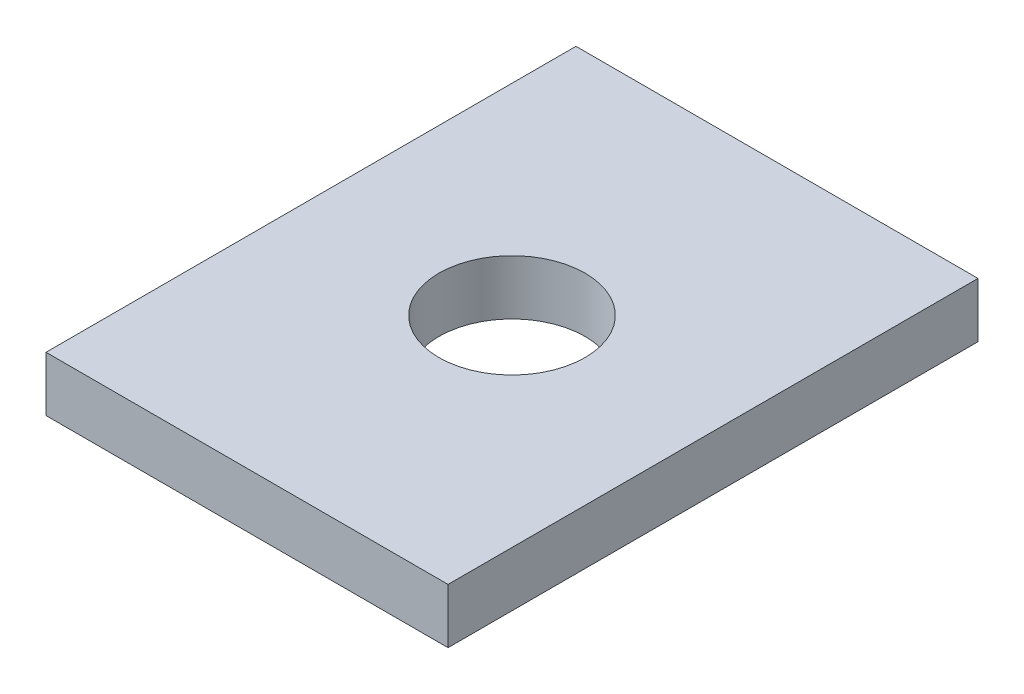
from build123d import *

# Parameters (mm, degrees)
SKETCH1_W           = 139.7
SKETCH1_H           = 184.15
SKETCH1_R           = 25.4
BOSS_EXTRUDE1_DEPTH = 19.05


with BuildPart() as part:
    # Sketch1 → Boss-Extrude1 (new body)
    with BuildSketch(Plane(origin=(0, 0, 0), x_dir=(1, 0, 0), z_dir=(0, 1, 0))):
        Rectangle(SKETCH1_W, SKETCH1_H)
        Circle(SKETCH1_R, mode=Mode.SUBTRACT)
    extrude(amount=BOSS_EXTRUDE1_DEPTH)


solid = part.part
